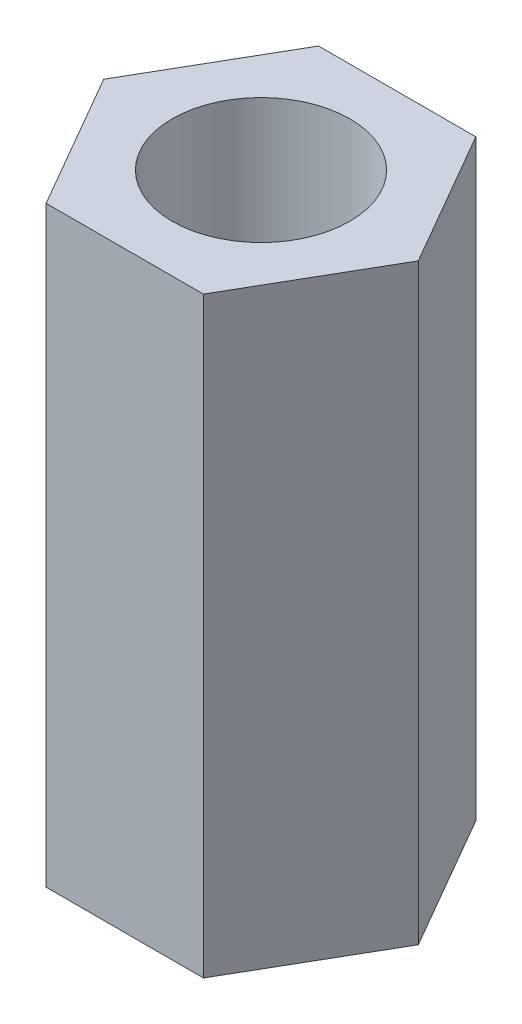
from build123d import *

# Parameters (mm, degrees)
SKETCH_1_R          = 1.5
EXTRUDE_2_DEPTH     = 5
SKETCH1_R           = 1.5
BOSS_EXTRUDE1_DEPTH = 5


with BuildPart() as part:
    # 草图1 → 凸台-拉伸2 (new body)
    with BuildSketch(Plane(origin=(0, 0, 0), x_dir=(1, 0, 0), z_dir=(0, 1, 0))):
        Polygon((-1.327905619, 2.3), (-2.655811238, 0), (-1.327905619, -2.3), (1.327905619, -2.3), (2.655811238, 0), (1.327905619, 2.3), align=None)
        Circle(SKETCH_1_R, mode=Mode.SUBTRACT)
    extrude(amount=EXTRUDE_2_DEPTH)

    # Sketch1 → Boss-Extrude1 (add)
    with BuildSketch(Plane(origin=(0, 5, 0), x_dir=(1, 0, 0), z_dir=(0, 1, 0))):
        Polygon((1.327905619, 2.3), (-1.327905619, 2.3), (-2.655811238, 0), (-1.327905619, -2.3), (1.327905619, -2.3), (2.655811238, 0), align=None)
        Circle(SKETCH1_R, mode=Mode.SUBTRACT)
    extrude(amount=BOSS_EXTRUDE1_DEPTH)


solid = part.part
